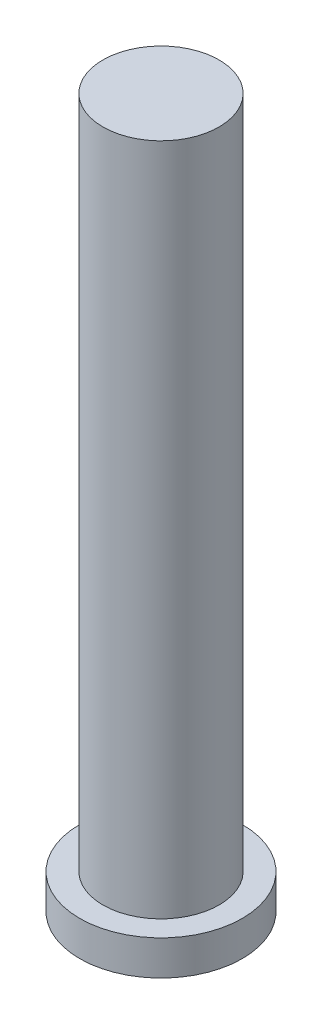
from build123d import *

# Parameters (mm, degrees)
SKETCH_1_R      = 7
EXTRUDE_1_DEPTH = 3
SKETCH_2_R      = 5
EXTRUDE_2_DEPTH = 58


with BuildPart() as part:
    # Эскиз1 → Бобышка-Вытянуть1 (new body)
    with BuildSketch(Plane(origin=(0, 0, 0), x_dir=(1, 0, 0), z_dir=(0, 1, 0))):
        Circle(SKETCH_1_R)
    extrude(amount=EXTRUDE_1_DEPTH)

    # Эскиз2 → Бобышка-Вытянуть2 (add)
    with BuildSketch(Plane(origin=(0, 3, 0), x_dir=(1, 0, 0), z_dir=(0, 1, 0))):
        Circle(SKETCH_2_R)
    extrude(amount=EXTRUDE_2_DEPTH)


solid = part.part
